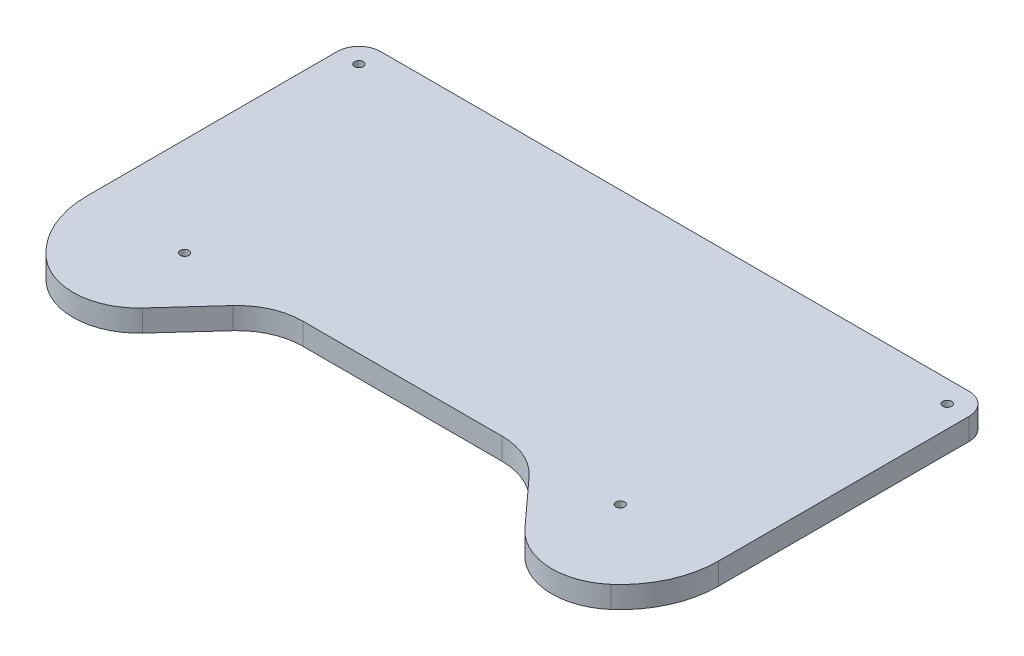
from build123d import *

# Parameters (mm, degrees)
ESQUISSE2_W              = 290
ESQUISSE2_H              = 184.53
BOSS_EXTRU_1_DEPTH       = 10
ESQUISSE9_R              = 2
ENL_V_MAT_EXTRU_7_DEPTH  = 10
ESQUISSE12_R             = 2
ENL_V_MAT_EXTRU_10_DEPTH = 10
ENL_V_MAT_EXTRU_12_DEPTH = 10
ENL_V_MAT_EXTRU_13_DEPTH = 10
CONG_1_R                 = 30
CONG_2_R                 = 30
ESQUISSE16_R             = 6
ENL_V_MAT_EXTRU_14_DEPTH = 5


with BuildPart() as part:
    # Esquisse2 → Boss.-Extru.1 (new body)
    with BuildSketch(Plane(origin=(0, 0, 0), x_dir=(1, 0, 0), z_dir=(0, 1, 0))):
        with Locations((145, 92.265)):
            Rectangle(ESQUISSE2_W, ESQUISSE2_H)
    extrude(amount=BOSS_EXTRU_1_DEPTH)

    # Esquisse9 → Enlèv. mat.-Extru.7 (cut)
    with BuildSketch(Plane(origin=(0, 10, 0), x_dir=(1, 0, 0), z_dir=(0, 1, 0))):
        with Locations((45, 50)):
            Circle(ESQUISSE9_R)
        with Locations((245, 50)):
            Circle(ESQUISSE9_R)
    extrude(amount=-ENL_V_MAT_EXTRU_7_DEPTH, mode=Mode.SUBTRACT)

    # Esquisse12 → Enlèv. mat.-Extru.10 (cut)
    with BuildSketch(Plane.XZ):
        with Locations((10, -165)):
            Circle(ESQUISSE12_R)
        with Locations((280, -165)):
            Circle(ESQUISSE12_R)
    extrude(amount=-ENL_V_MAT_EXTRU_10_DEPTH, mode=Mode.SUBTRACT)

    # Esquisse14 → Enlèv. mat.-Extru.12 (cut)
    with BuildSketch(Plane(origin=(0, 10, 0), x_dir=(1, 0, 0), z_dir=(0, 1, 0))):
        with BuildLine():
            Line((0, 184.53), (0, 165))
            ThreePointArc((0, 165), (2.928932188, 172.071067812), (10, 175))
            Line((10, 175), (280, 175))
            ThreePointArc((280, 175), (287.071067812, 172.071067812), (290, 165))
            Line((290, 165), (290, 184.53))
            Line((290, 184.53), (0, 184.53))
        make_face()
        with BuildLine():
            Line((245, 5), (45, 5))
            ThreePointArc((45, 5), (13.180194847, 18.180194847), (0, 50))
            Line((0, 50), (0, 0))
            Line((0, 0), (290, 0))
            Line((290, 0), (290, 50))
            ThreePointArc((290, 50), (276.819805153, 18.180194847), (245, 5))
        make_face()
    extrude(amount=-ENL_V_MAT_EXTRU_12_DEPTH, mode=Mode.SUBTRACT)

    # Esquisse15 → Enlèv. mat.-Extru.13 (cut)
    with BuildSketch(Plane(origin=(0, 10, 0), x_dir=(1, 0, 0), z_dir=(0, 1, 0))):
        Polygon((245, 5), (203.974576033, 50), (86.025423967, 50), (45, 5), align=None)
    extrude(amount=-ENL_V_MAT_EXTRU_13_DEPTH, mode=Mode.SUBTRACT)

    # Congé1
    cong_1_edges = [part.edges().sort_by_distance(p)[0] for p in [
        (86.025423967, 5, -50),
        (203.974576033, 5, -50),
    ]]
    fillet(cong_1_edges, radius=CONG_1_R)

    # Congé2
    cong_2_edges = [part.edges().sort_by_distance(p)[0] for p in [
        (45, 5, -5),
        (245, 5, -5),
    ]]
    fillet(cong_2_edges, radius=CONG_2_R)

    # Esquisse16 → Enlèv. mat.-Extru.14 (cut)
    with BuildSketch(Plane.XZ):
        with Locations((45, -50)):
            Circle(ESQUISSE16_R)
        with Locations((245, -50)):
            Circle(ESQUISSE16_R)
        with Locations((280, -165)):
            Circle(ESQUISSE16_R)
        with Locations((10, -165)):
            Circle(ESQUISSE16_R)
    extrude(amount=-ENL_V_MAT_EXTRU_14_DEPTH, mode=Mode.SUBTRACT)


solid = part.part
